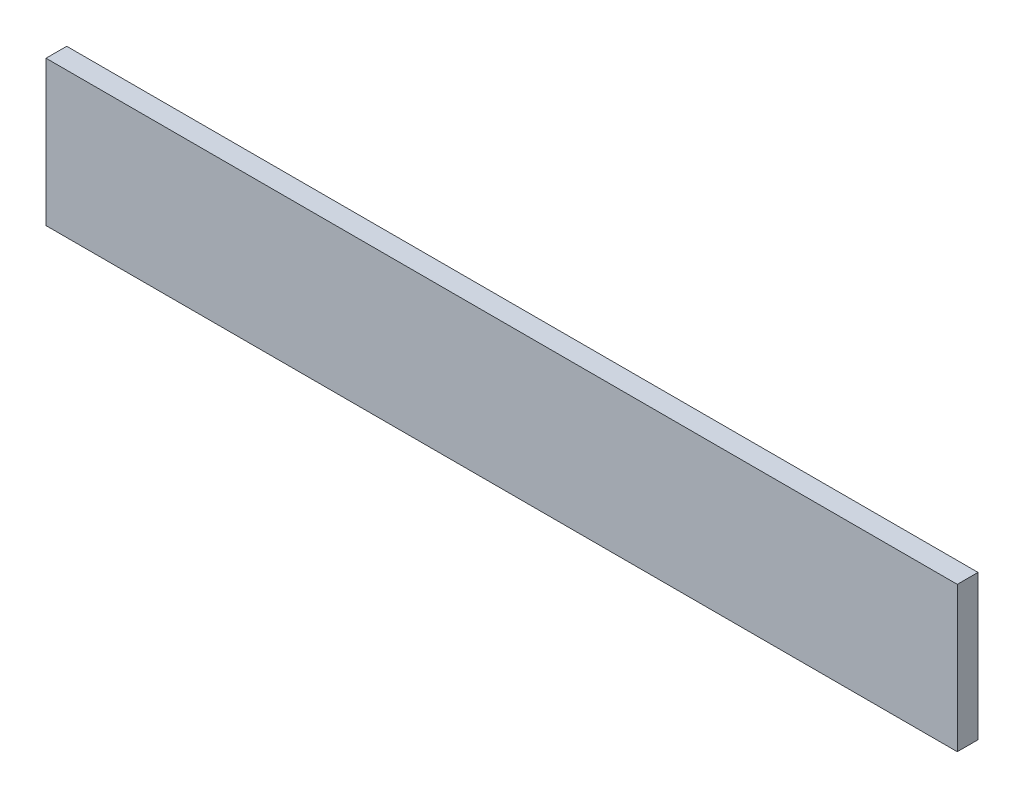
from build123d import *

# Parameters (mm, degrees)
CROQUIS1_W              = 220
CROQUIS1_H              = 35
SALIENTE_EXTRUIR1_DEPTH = 5


with BuildPart() as part:
    # Croquis1 → Saliente-Extruir1 (new body)
    with BuildSketch(Plane.XY):
        with Locations((110, 17.5)):
            Rectangle(CROQUIS1_W, CROQUIS1_H)
    extrude(amount=SALIENTE_EXTRUIR1_DEPTH)


solid = part.part
